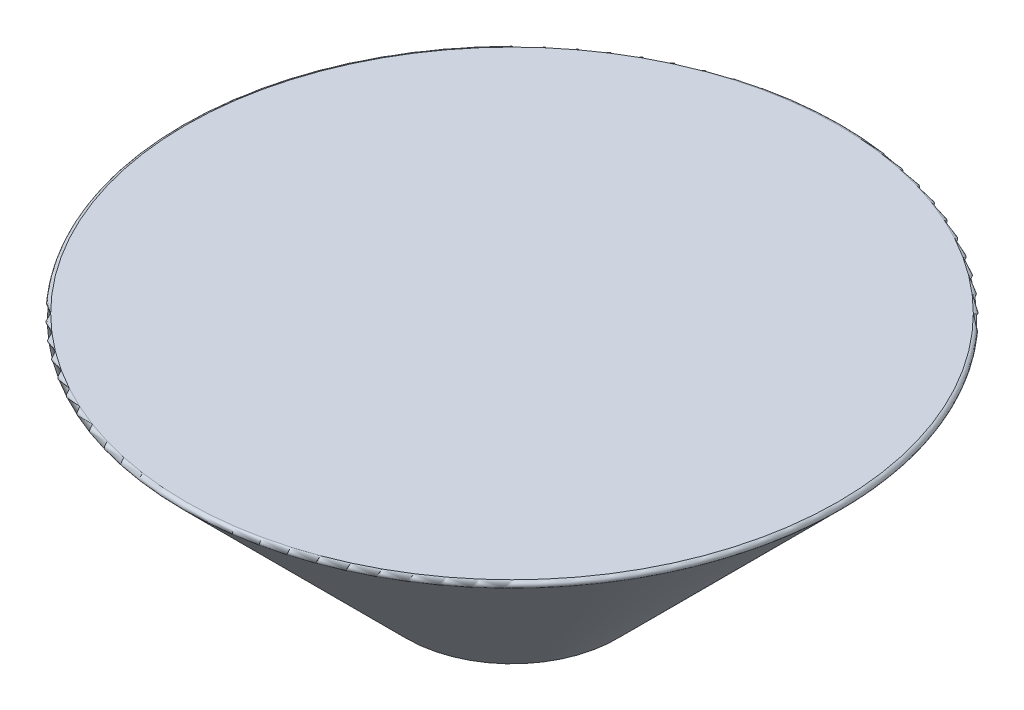
from build123d import *

# Parameters (mm, degrees)
FILLET3_R = 0.5


with BuildPart() as part:
    # Sketch1 → Revolve1 (revolve)
    with BuildSketch(Plane.XY):
        with BuildLine():
            Line((0, 0), (0, -39.64))
            ThreePointArc((0, -39.64), (8.30879609, -38.261299735), (15.727027303, -34.272972697))
            Line((15.727027303, -34.272972697), (50, 0))
            Line((50, 0), (0, 0))
        make_face()
    revolve(axis=Axis((0, 0, 0), (0, -1, 0)))

    # Fillet3
    fillet3_edges = [part.edges().sort_by_distance(p)[0] for p in [
        (-50, 0, 0),
    ]]
    fillet(fillet3_edges, radius=FILLET3_R)


solid = part.part
